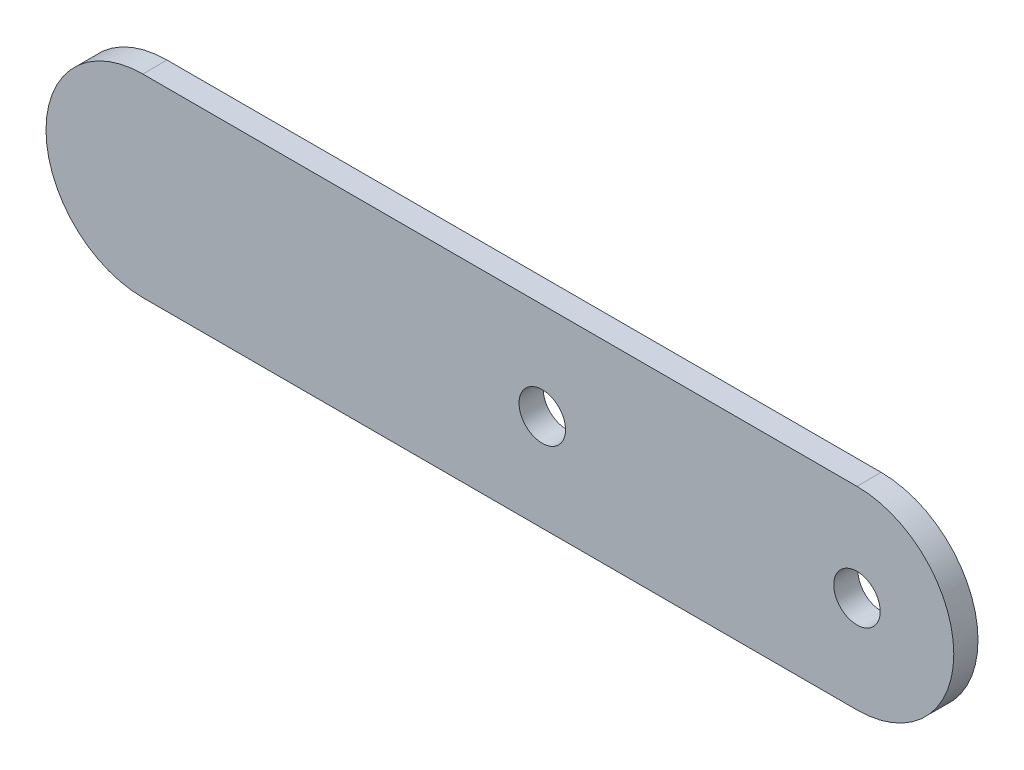
from build123d import *

# Parameters (mm, degrees)
SKETCH1_R           = 3.048
BOSS_EXTRUDE1_DEPTH = 3.175


with BuildPart() as part:
    # Sketch1 → Boss-Extrude1 (new body)
    with BuildSketch(Plane.XY):
        with BuildLine():
            Line((-46.83125, -12.7), (46.83125, -12.7))
            ThreePointArc((46.83125, -12.7), (59.53125, 0), (46.83125, 12.7))
            Line((46.83125, 12.7), (-46.83125, 12.7))
            ThreePointArc((-46.83125, 12.7), (-59.53125, 0), (-46.83125, -12.7))
        make_face()
        with Locations((46.83125, 0)):
            Circle(SKETCH1_R, mode=Mode.SUBTRACT)
        with Locations((5.55625, 0)):
            Circle(SKETCH1_R, mode=Mode.SUBTRACT)
    extrude(amount=BOSS_EXTRUDE1_DEPTH)


solid = part.part
